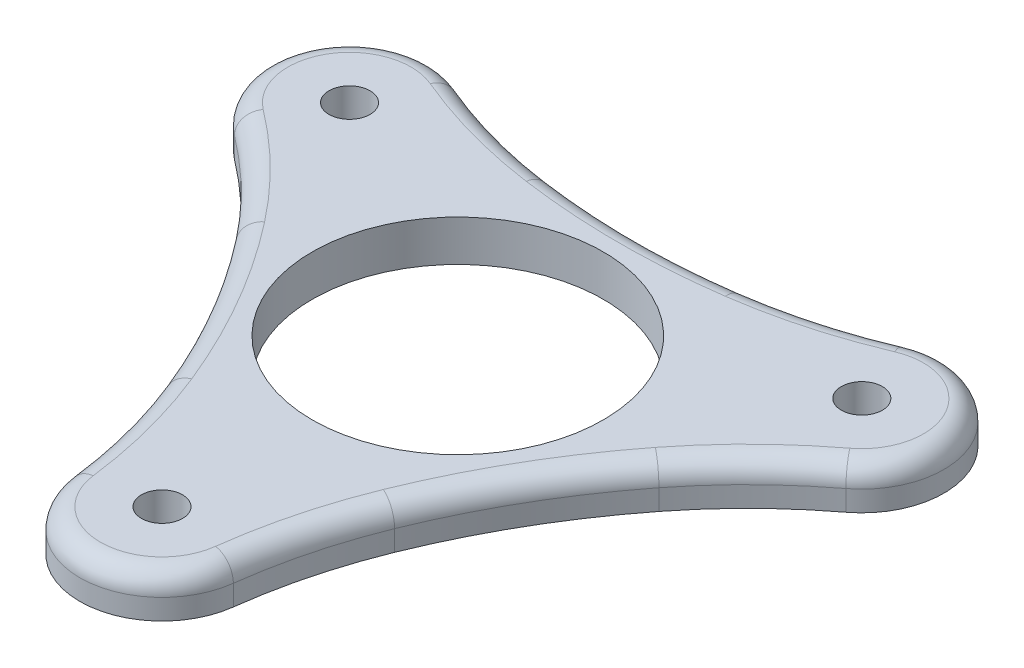
from build123d import *

# Parameters (mm, degrees)
SKETCH1_R           = 22.5
SKETCH1_R_2         = 3.175
BOSS_EXTRUDE4_DEPTH = 6.35
FILLET1_R           = 78.74
FILLET3_R           = 3.175


with BuildPart() as part:
    # Sketch1 → Boss-Extrude4 (new body)
    with BuildSketch(Plane(origin=(0, 0, 0), x_dir=(1, 0, 0), z_dir=(0, 1, 0))):
        with BuildLine():
            ThreePointArc((-12.576911226, -43.956111111), (0, -58.42), (12.576911226, -43.956111111))
            ThreePointArc((12.576911226, -43.956111111), (24.319961907, -14.041136553), (44.355564487, 11.086130933))
            ThreePointArc((44.355564487, 11.086130933), (50.593204089, 29.21), (31.778653261, 32.869980178))
            ThreePointArc((31.778653261, 32.869980178), (0, 28.082273107), (-31.778653261, 32.869980178))
            ThreePointArc((-31.778653261, 32.869980178), (-50.593204089, 29.21), (-44.355564487, 11.086130933))
            ThreePointArc((-44.355564487, 11.086130933), (-24.319961907, -14.041136553), (-12.576911226, -43.956111111))
        make_face()
        Circle(SKETCH1_R, mode=Mode.SUBTRACT)
        with Locations((0, -45.72)):
            Circle(SKETCH1_R_2, mode=Mode.SUBTRACT)
        with Locations((-39.594681461, 22.86)):
            Circle(SKETCH1_R_2, mode=Mode.SUBTRACT)
        with Locations((39.594681461, 22.86)):
            Circle(SKETCH1_R_2, mode=Mode.SUBTRACT)
    extrude(amount=BOSS_EXTRUDE4_DEPTH)

    # Fillet1
    fillet1_edges = [part.edges().sort_by_distance(p)[0] for p in [
        (-12.576911226, 3.175, 43.956111111),
        (-44.355564487, 3.175, -11.086130933),
        (-31.778653261, 3.175, -32.869980178),
        (31.778653261, 3.175, -32.869980178),
        (44.355564487, 3.175, -11.086130933),
        (12.576911226, 3.175, 43.956111111),
    ]]
    fillet(fillet1_edges, radius=FILLET1_R)

    # Fillet3
    fillet3_edges = [part.edges().sort_by_distance(p)[0] for p in [
        (0, 6.35, -28.082273107),
        (50.593204089, 6.35, -29.21),
        (-50.593204089, 6.35, -29.21),
        (-24.319961907, 6.35, 14.041136554),
        (0, 6.35, 58.42),
        (24.319961907, 6.35, 14.041136553),
        (24.983104272, 6.35, -31.200471163),
        (-24.983104272, 6.35, -31.200471163),
        (-39.511952773, 6.35, -6.035767384),
        (-14.528848501, 6.35, 37.236238547),
        (14.528848501, 6.35, 37.236238547),
        (39.511952773, 6.35, -6.035767384),
    ]]
    fillet(fillet3_edges, radius=FILLET3_R)


solid = part.part
